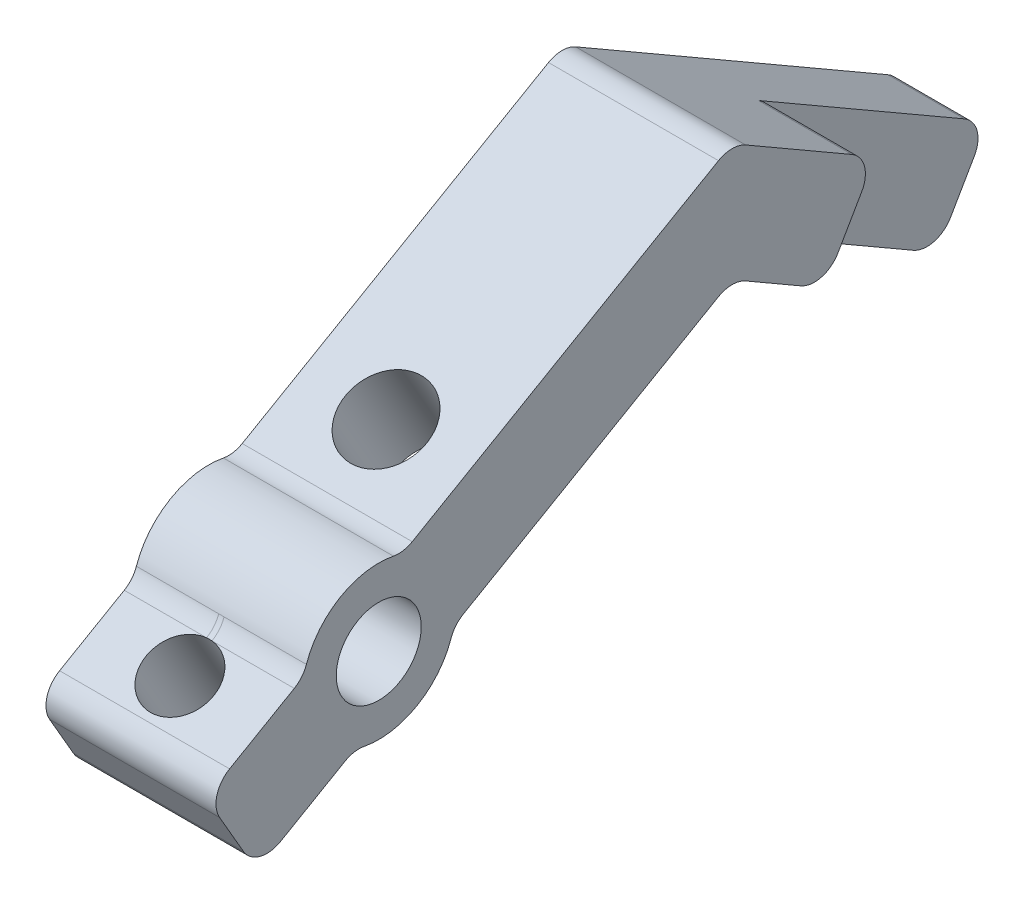
from build123d import *

# Parameters (mm, degrees)
SKETCH1_R           = 3.96875
BOSS_EXTRUDE1_DEPTH = 15.875
SKETCH2_R           = 3.175
SKETCH2_R_2         = 3.81
CUT_EXTRUDE1_DEPTH  = 9.525
CUT_EXTRUDE2_DEPTH  = 8.73125
FILLET1_R           = 2.54


with BuildPart() as part:
    # Sketch1 → Boss-Extrude1 (new body)
    with BuildSketch(Plane(origin=(0, 0, 0), x_dir=(0, 0, -1), z_dir=(1, 0, 0))):
        with BuildLine():
            ThreePointArc((-2.230020797, 12.263235579), (-6.186668978, 15.478125), (-6.992520797, 20.51212755))
            Line((-6.992520797, 20.51212755), (-16.129403285, 15.236945986))
            Line((-16.129403285, 15.236945986), (-11.366903285, 6.988054014))
            Line((-11.366903285, 6.988054014), (-2.230020797, 12.263235579))
        make_face()
        with BuildLine():
            Line((-6.992520797, 20.51212755), (2.230020797, 25.836764421))
            ThreePointArc((2.230020797, 25.836764421), (-3.571875, 25.236668978), (-6.992520797, 20.51212755))
        make_face()
        with BuildLine():
            Line((6.992520797, 17.58787245), (-2.230020797, 12.263235579))
            ThreePointArc((-2.230020797, 12.263235579), (3.571875, 12.863331022), (6.992520797, 17.58787245))
        make_face()
        with BuildLine():
            Line((65.622755111, 24.761945986), (32.995567884, 43.599261314))
            Line((32.995567884, 43.599261314), (2.230020797, 25.836764421))
            ThreePointArc((2.230020797, 25.836764421), (5.786357884, 23.239418396), (7.14375, 19.05))
            ThreePointArc((7.14375, 19.05), (7.105842121, 18.315036184), (6.992520797, 17.58787245))
            Line((6.992520797, 17.58787245), (32.995567884, 32.600738686))
            Line((32.995567884, 32.600738686), (60.860255111, 16.513054014))
            Line((60.860255111, 16.513054014), (65.622755111, 24.761945986))
        make_face()
        with BuildLine():
            ThreePointArc((7.14375, 19.05), (5.786357884, 23.239418396), (2.230020797, 25.836764421))
            Line((2.230020797, 25.836764421), (-6.992520797, 20.51212755))
            ThreePointArc((-6.992520797, 20.51212755), (-6.186668978, 15.478125), (-2.230020797, 12.263235579))
            Line((-2.230020797, 12.263235579), (6.992520797, 17.58787245))
            ThreePointArc((6.992520797, 17.58787245), (7.105842121, 18.315036184), (7.14375, 19.05))
        make_face()
        with Locations((0, 19.05)):
            Circle(SKETCH1_R, mode=Mode.SUBTRACT)
    extrude(amount=BOSS_EXTRUDE1_DEPTH)

    # Sketch2 → Cut-Extrude1 (cut)
    with BuildSketch(Plane(origin=(0, 18.411945986, 10.630141971), x_dir=(1, 0, 0), z_dir=(0, 0.866025404, 0.5))):
        with Locations((7.9375, 0)):
            Circle(SKETCH2_R)
        with Locations((7.9375, 22.225)):
            Circle(SKETCH2_R_2)
    extrude(amount=-CUT_EXTRUDE1_DEPTH, mode=Mode.SUBTRACT)

    # Sketch3 → Cut-Extrude2 (cut)
    with BuildSketch(Plane(origin=(15.875, 0, 0), x_dir=(0, 0, -1), z_dir=(1, 0, 0))):
        Polygon((65.622755111, 24.761945986), (60.860255111, 16.513054014), (41.612840512, 27.625554014), (46.375340512, 35.874445986), align=None)
    extrude(amount=-CUT_EXTRUDE2_DEPTH, mode=Mode.SUBTRACT)

    # Fillet1
    fillet1_edges = [part.edges().sort_by_distance(p)[0] for p in [
        (7.9375, 6.988054014, 11.366903285),
        (7.9375, 15.236945986, 16.129403285),
        (7.9375, 20.51212755, 6.992520797),
        (7.9375, 25.836764421, -2.230020797),
        (7.9375, 43.599261314, -32.995567884),
        (7.9375, 32.600738686, -32.995567884),
        (7.9375, 17.58787245, -6.992520797),
        (7.9375, 12.263235579, 2.230020797),
        (3.571875, 24.761945986, -65.622755111),
        (3.571875, 16.513054014, -60.860255111),
        (11.509375, 35.874445986, -46.375340512),
        (11.509375, 27.625554014, -41.612840512),
    ]]
    fillet(fillet1_edges, radius=FILLET1_R)


solid = part.part
